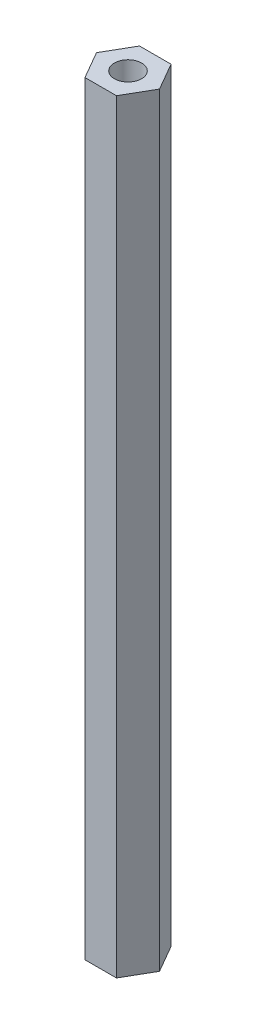
from build123d import *

# Parameters (mm, degrees)
SKETCH1_R           = 1.5875
BOSS_EXTRUDE1_DEPTH = 88.9


with BuildPart() as part:
    # Sketch1 → Boss-Extrude1 (new body)
    with BuildSketch(Plane(origin=(0, 0, 0), x_dir=(1, 0, 0), z_dir=(0, 1, 0))):
        Polygon((1.833087105, 3.175), (-1.833087105, 3.175), (-3.666174209, 0), (-1.833087105, -3.175), (1.833087105, -3.175), (3.666174209, 0), align=None)
        Circle(SKETCH1_R, mode=Mode.SUBTRACT)
    extrude(amount=BOSS_EXTRUDE1_DEPTH)


solid = part.part
